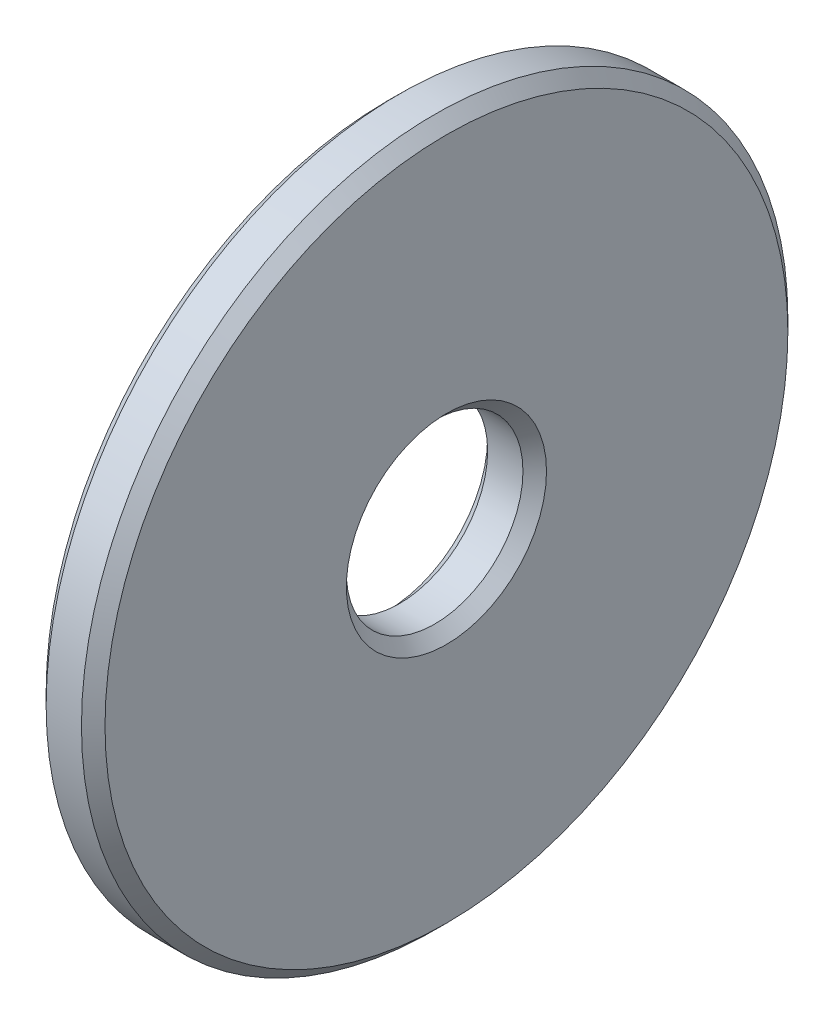
from build123d import *


with BuildPart() as part:
    # Sketch1 → Revolve1 (revolve)
    with BuildSketch(Plane.XY):
        Polygon((0, 5.8), (0, 1.7), (0.2, 1.5), (0.8, 1.5), (1, 1.7), (1, 5.8), (0.8, 6), (0.2, 6), align=None)
    revolve(axis=Axis((0, 0, 0), (1, 0, 0)))


solid = part.part
